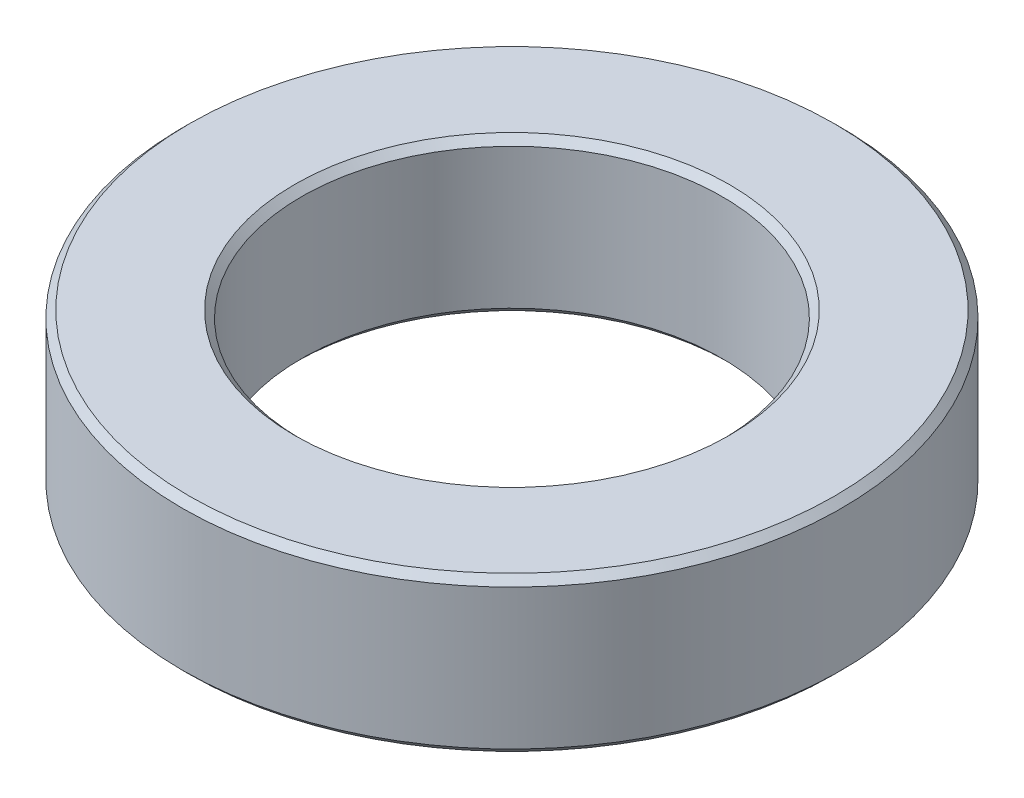
from build123d import *

# Parameters (mm, degrees)
SKETCH_1_R      = 23.5
SKETCH_1_R_2    = 15
EXTRUDE_1_DEPTH = 11
CHAMFER_1_SIZE  = 0.5


with BuildPart() as part:
    # 草图1 → 凸台-拉伸1 (new body)
    with BuildSketch(Plane(origin=(0, 0, 0), x_dir=(1, 0, 0), z_dir=(0, 1, 0))):
        Circle(SKETCH_1_R)
        Circle(SKETCH_1_R_2, mode=Mode.SUBTRACT)
    extrude(amount=EXTRUDE_1_DEPTH)

    # 倒角1
    chamfer_1_edges = [part.edges().sort_by_distance(p)[0] for p in [
        (-23.5, 0, 0),
        (-23.5, 11, 0),
        (-15, 0, 0),
        (-15, 11, 0),
    ]]
    chamfer(chamfer_1_edges, length=CHAMFER_1_SIZE)


solid = part.part
